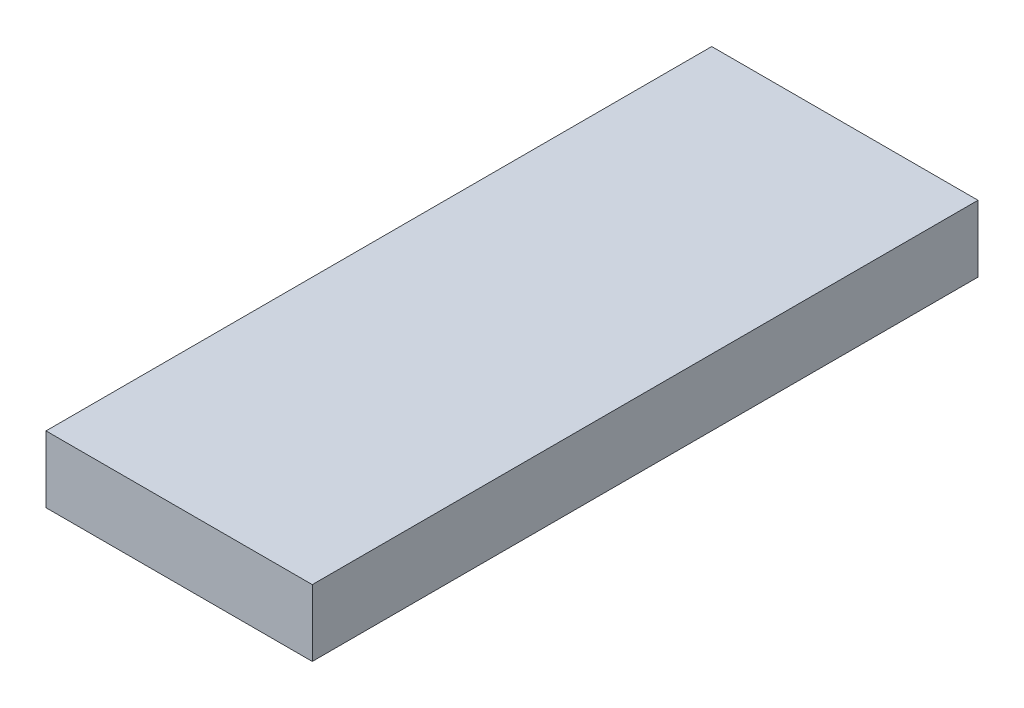
from build123d import *

# Parameters (mm, degrees)
SKETCH1_W           = 40
SKETCH1_H           = 100
BOSS_EXTRUDE1_DEPTH = 10


with BuildPart() as part:
    # Sketch1 → Boss-Extrude1 (new body)
    with BuildSketch(Plane(origin=(0, 0, 0), x_dir=(1, 0, 0), z_dir=(0, 1, 0))):
        Rectangle(SKETCH1_W, SKETCH1_H)
    extrude(amount=BOSS_EXTRUDE1_DEPTH)


solid = part.part
